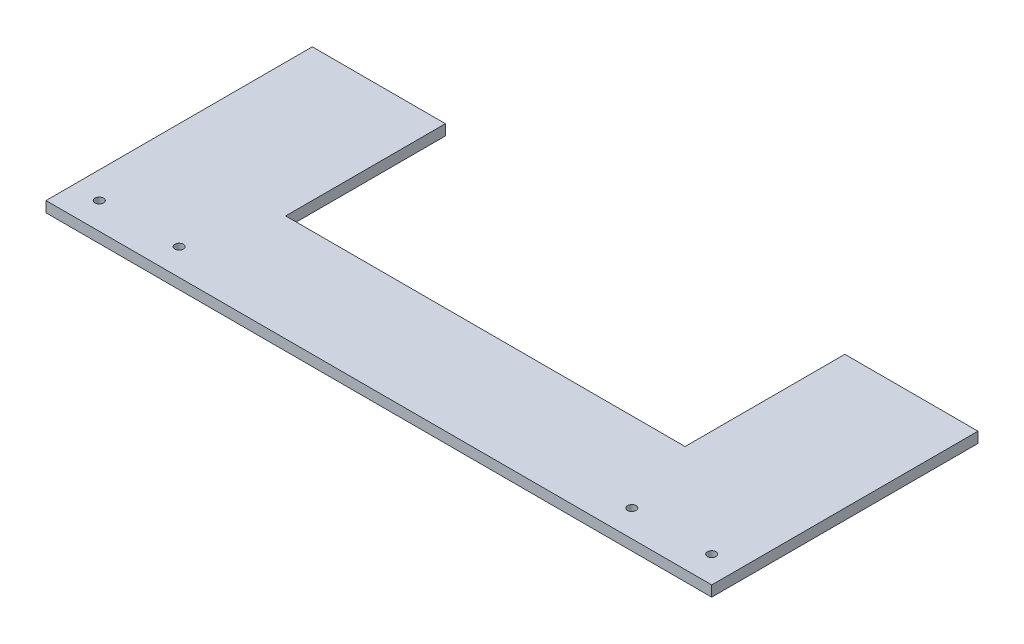
from build123d import *

# Parameters (mm, degrees)
SKETCH_1_W          = 250
SKETCH_1_H          = 100
SKETCH_1_R          = 1.6
EXTRUDE_1_DEPTH     = 4
CUT_EXTRUDE_1_DEPTH = 5


with BuildPart() as part:
    # 草图1 → 凸台-拉伸1 (new body)
    with BuildSketch(Plane(origin=(0, 0, 0), x_dir=(1, 0, 0), z_dir=(0, 1, 0))):
        Rectangle(SKETCH_1_W, SKETCH_1_H)
        with Locations((-115, -40)):
            Circle(SKETCH_1_R, mode=Mode.SUBTRACT)
        with Locations((-85, -40)):
            Circle(SKETCH_1_R, mode=Mode.SUBTRACT)
        with Locations((85, -40)):
            Circle(SKETCH_1_R, mode=Mode.SUBTRACT)
        with Locations((115, -40)):
            Circle(SKETCH_1_R, mode=Mode.SUBTRACT)
    extrude(amount=EXTRUDE_1_DEPTH)

    # 草图2 → 切除-拉伸1 (cut, through all)
    with BuildSketch(Plane(origin=(0, 4, 0), x_dir=(1, 0, 0), z_dir=(0, 1, 0))):
        Polygon((74.999994093, 50), (74.999998028, -10), (-74.999998028, -10), (-74.999994093, 50), align=None)
    extrude(amount=-CUT_EXTRUDE_1_DEPTH, mode=Mode.SUBTRACT)


solid = part.part
